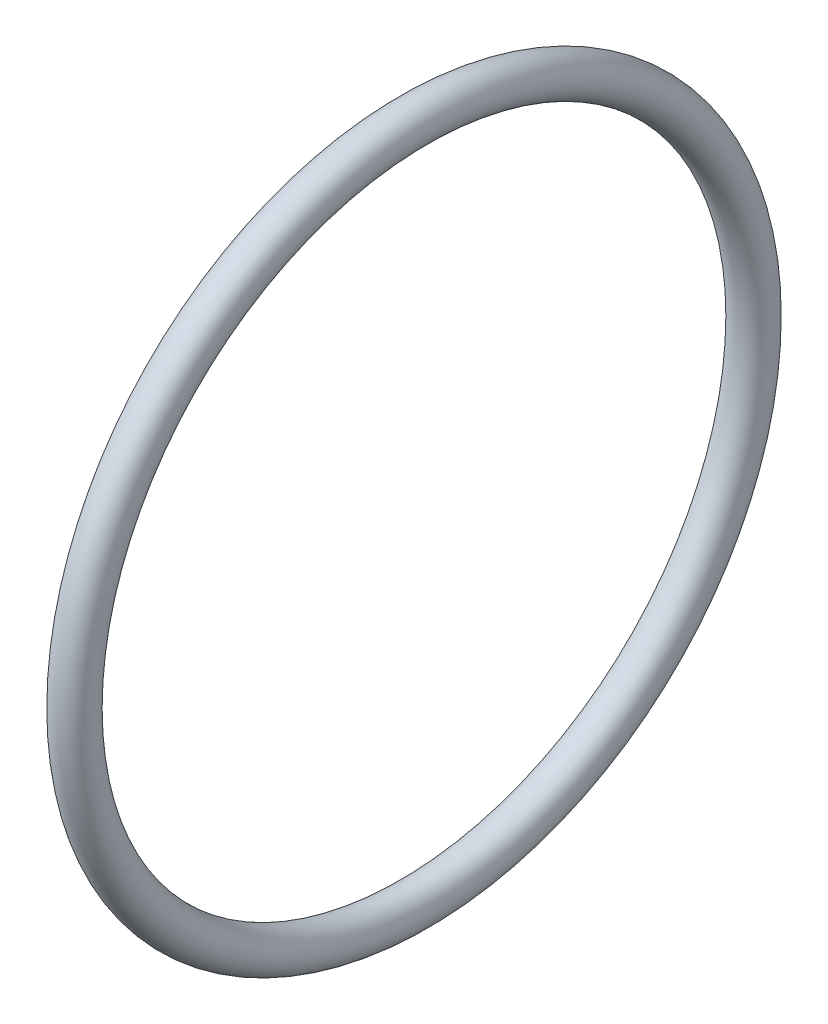
from build123d import *

# Parameters (mm, degrees)
SKETCH_5_R = 0.75


with BuildPart() as part:
    # Эскиз5 → Повернуть1 (revolve)
    with BuildSketch(Plane(origin=(0, 0, 0), x_dir=(1, 0, 0), z_dir=(0, 1, 0))):
        with Locations((-2.114173566, 13)):
            Circle(SKETCH_5_R)
    revolve(axis=Axis((-35.861143609, 0, 0), (1, 0, 0)))


solid = part.part
